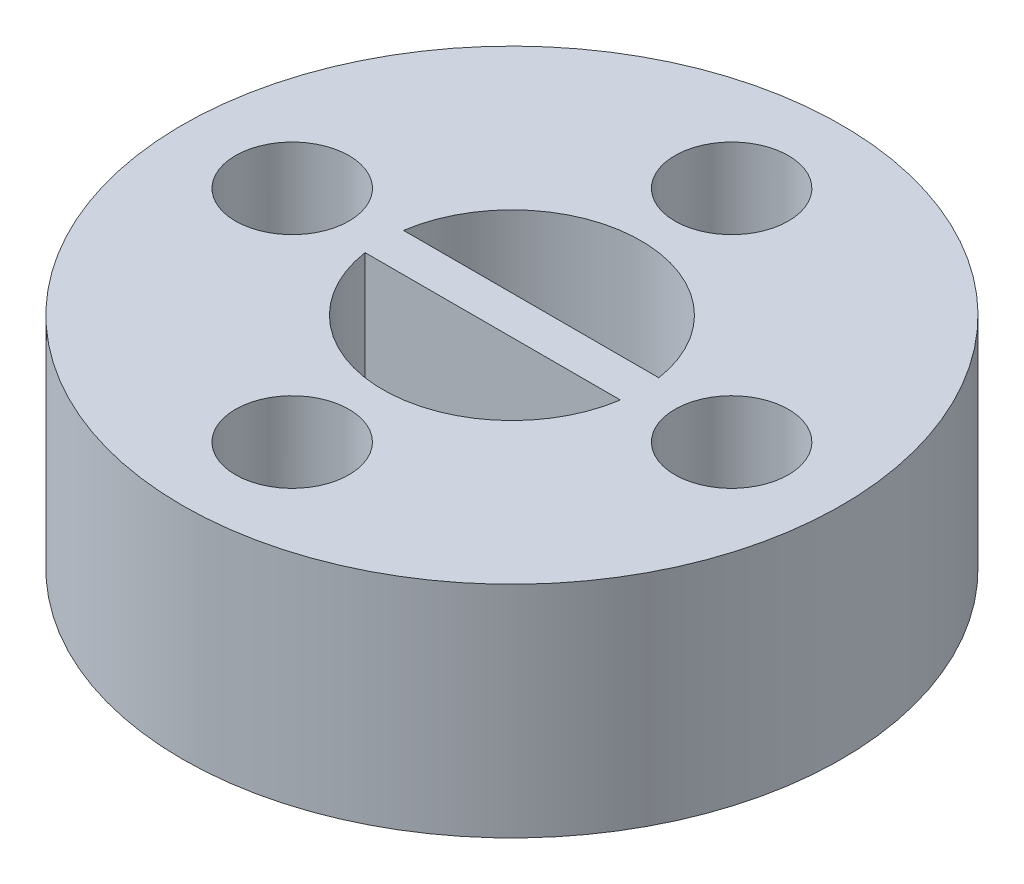
from build123d import *

# Parameters (mm, degrees)
SKETCH1_R           = 9
SKETCH1_R_2         = 3.525
BOSS_EXTRUDE1_DEPTH = 6
SKETCH2_W           = 7.05
SKETCH2_H           = 1.05
BOSS_EXTRUDE2_DEPTH = 6
SKETCH3_R           = 1.55
CUT_EXTRUDE1_DEPTH  = 8
CIRPATTERN1_COUNT   = 4


with BuildPart() as part:
    # Sketch1 → Boss-Extrude1 (new body)
    with BuildSketch(Plane(origin=(0, 0, 0), x_dir=(1, 0, 0), z_dir=(0, 1, 0))):
        Circle(SKETCH1_R)
        Circle(SKETCH1_R_2, mode=Mode.SUBTRACT)
    extrude(amount=BOSS_EXTRUDE1_DEPTH)

    # Sketch2 → Boss-Extrude2 (add)
    with BuildSketch(Plane(origin=(0, 0, 0), x_dir=(1, 0, 0), z_dir=(0, 1, 0))):
        Rectangle(SKETCH2_W, SKETCH2_H)
    extrude(amount=BOSS_EXTRUDE2_DEPTH)

    # Sketch3 → Cut-Extrude1 (cut)
    with BuildSketch(Plane(origin=(0, 6, 0), x_dir=(1, 0, 0), z_dir=(0, 1, 0))):
        with Locations((6, 0)):
            Circle(SKETCH3_R)
    cut_extrude1 = extrude(amount=-CUT_EXTRUDE1_DEPTH, mode=Mode.SUBTRACT)

    # CirPattern1: Cut-Extrude1 ×4 about axis
    cirpattern1_axis = Axis((0, 0, 0), (0, 1, 0))
    for i in range(1, CIRPATTERN1_COUNT):
        add(cut_extrude1.rotate(cirpattern1_axis, i * 360 / CIRPATTERN1_COUNT), mode=Mode.SUBTRACT)


solid = part.part
